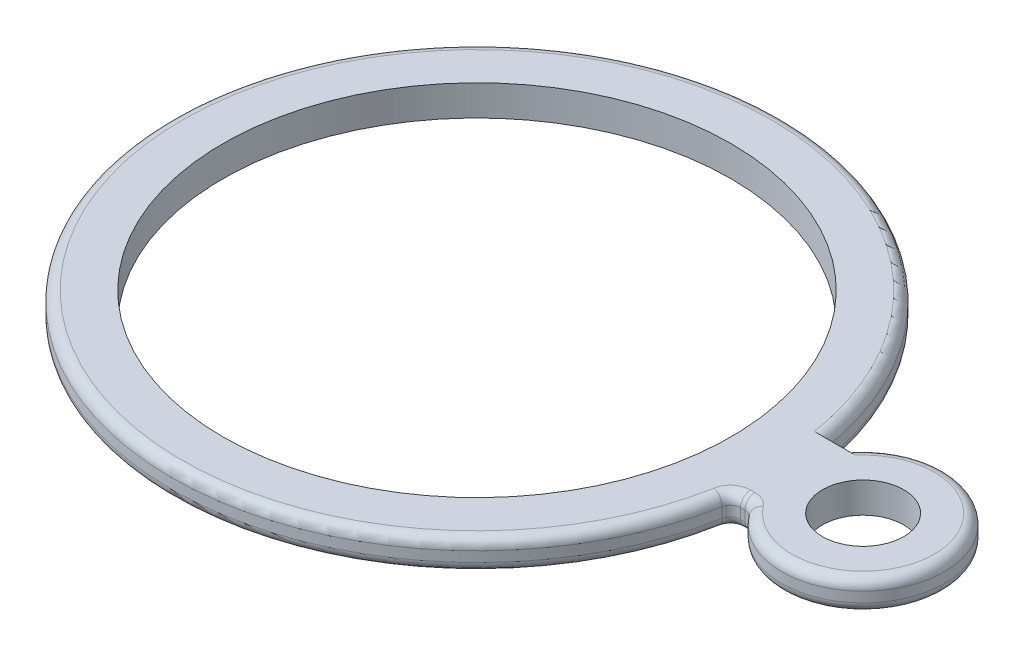
from build123d import *

# Parameters (mm, degrees)
SKETCH1_R           = 25
SKETCH1_R_2         = 4
BOSS_EXTRUDE1_DEPTH = 3
FILLET1_R           = 1


with BuildPart() as part:
    # Sketch1 → Boss-Extrude1 (new body)
    with BuildSketch(Plane(origin=(0, 0, 0), x_dir=(1, 0, 0), z_dir=(0, 1, 0))):
        with BuildLine():
            Line((31.428037515, 4.561722164), (29.651149909, 4.561722164))
            ThreePointArc((29.651149909, 4.561722164), (-30, 0), (29.651149909, -4.561722164))
            Line((29.651149909, -4.561722164), (31.428037515, -4.561722164))
            ThreePointArc((31.428037515, -4.561722164), (46, 0), (31.428037515, 4.561722164))
        make_face()
        Circle(SKETCH1_R, mode=Mode.SUBTRACT)
        with Locations((38, 0)):
            Circle(SKETCH1_R_2, mode=Mode.SUBTRACT)
    extrude(amount=BOSS_EXTRUDE1_DEPTH)

    # Fillet1
    fillet1_edges = [part.edges().sort_by_distance(p)[0] for p in [
        (30.539593712, 0, 4.561722164),
        (-30, 0, 0),
        (30.539593712, 3, 4.561722164),
        (31.428037515, 1.5, 4.561722164),
        (29.651149909, 1.5, 4.561722164),
        (46, 3, 0),
        (-30, 3, 0),
        (46, 0, 0),
    ]]
    fillet(fillet1_edges, radius=FILLET1_R)


solid = part.part
